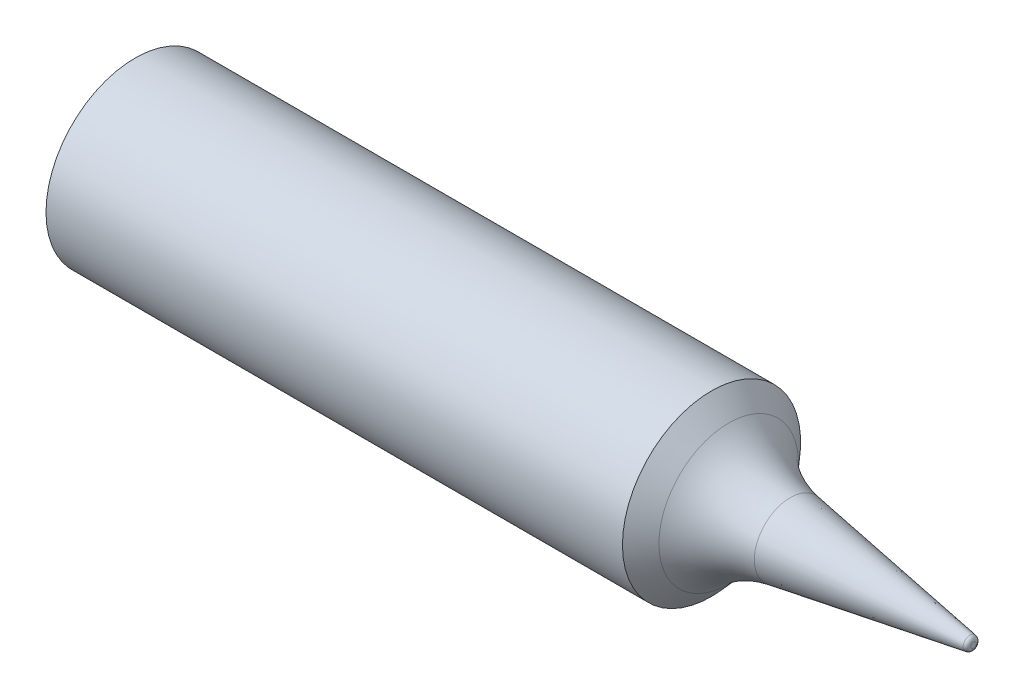
from build123d import *


with BuildPart() as part:
    # Esquisse1 → Révolution1 (revolve)
    with BuildSketch(Plane.XY):
        with BuildLine():
            Line((0, 3.3), (0, 4.25))
            Line((0, 4.25), (0.95, 4.25))
            Line((0.95, 4.25), (27.5, 4.25))
            Line((27.5, 4.25), (28.318139594, 3.329592957))
            ThreePointArc((28.318139594, 3.329592957), (29.647828221, 2.26910367), (31.256068325, 1.715684176))
            Line((31.256068325, 1.715684176), (39.831964715, 0.327205713))
            ThreePointArc((39.831964715, 0.327205713), (39.952303879, 0.259405019), (40, 0.129776594))
            Line((40, 0.129776594), (40, 0))
            Line((40, 0), (30.006720572, 0))
            Line((30.006720572, 0), (27.073387239, 3.3))
            Line((27.073387239, 3.3), (0, 3.3))
        make_face()
    revolve(axis=Axis((0, 0, 0), (1, 0, 0)))


solid = part.part
